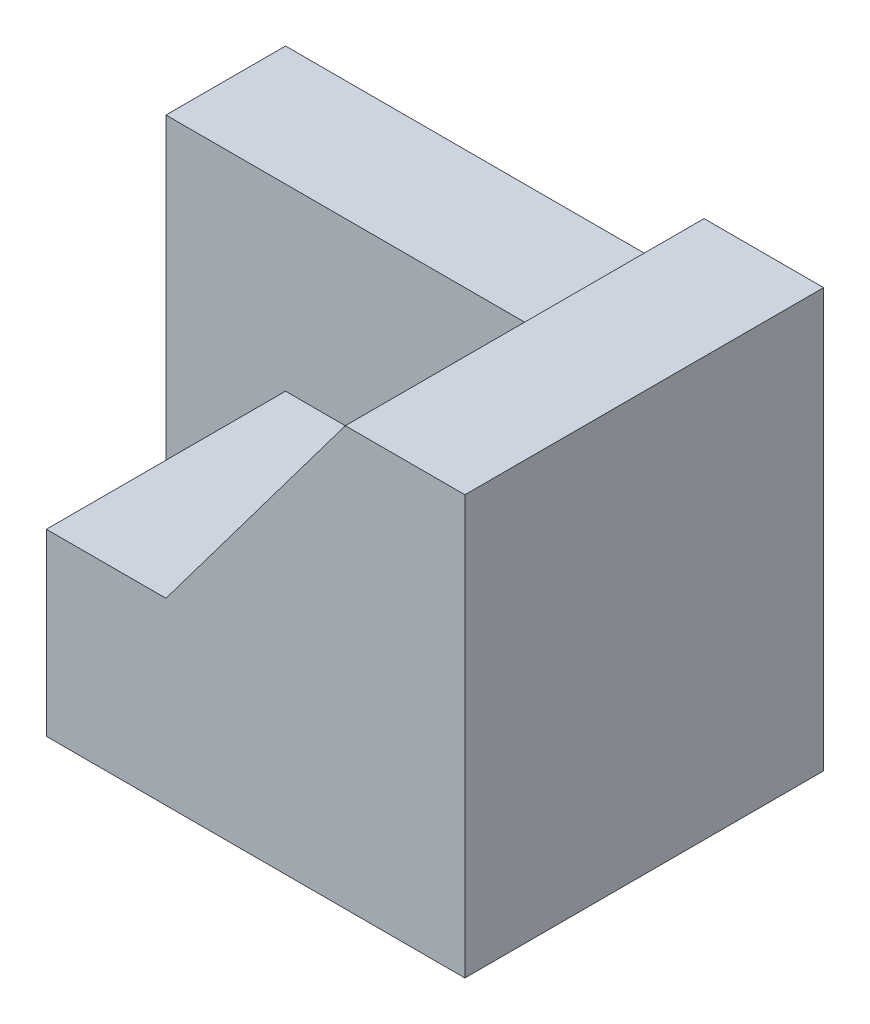
from build123d import *

# Parameters (mm, degrees)
SKETCH1_W           = 90
SKETCH1_H           = 60
BOSS_EXTRUDE1_DEPTH = 20
BOSS_EXTRUDE2_DEPTH = 60


with BuildPart() as part:
    # Sketch1 → Boss-Extrude1 (new body)
    with BuildSketch(Plane.XY):
        with Locations((45, 30)):
            Rectangle(SKETCH1_W, SKETCH1_H)
    extrude(amount=BOSS_EXTRUDE1_DEPTH)

    # Sketch2 → Boss-Extrude2 (add)
    with BuildSketch(Plane.XY):
        Polygon((20, 0), (20, 30), (40, 30), (70, 70), (90, 70), (90, 0), align=None)
    extrude(amount=BOSS_EXTRUDE2_DEPTH)


solid = part.part
